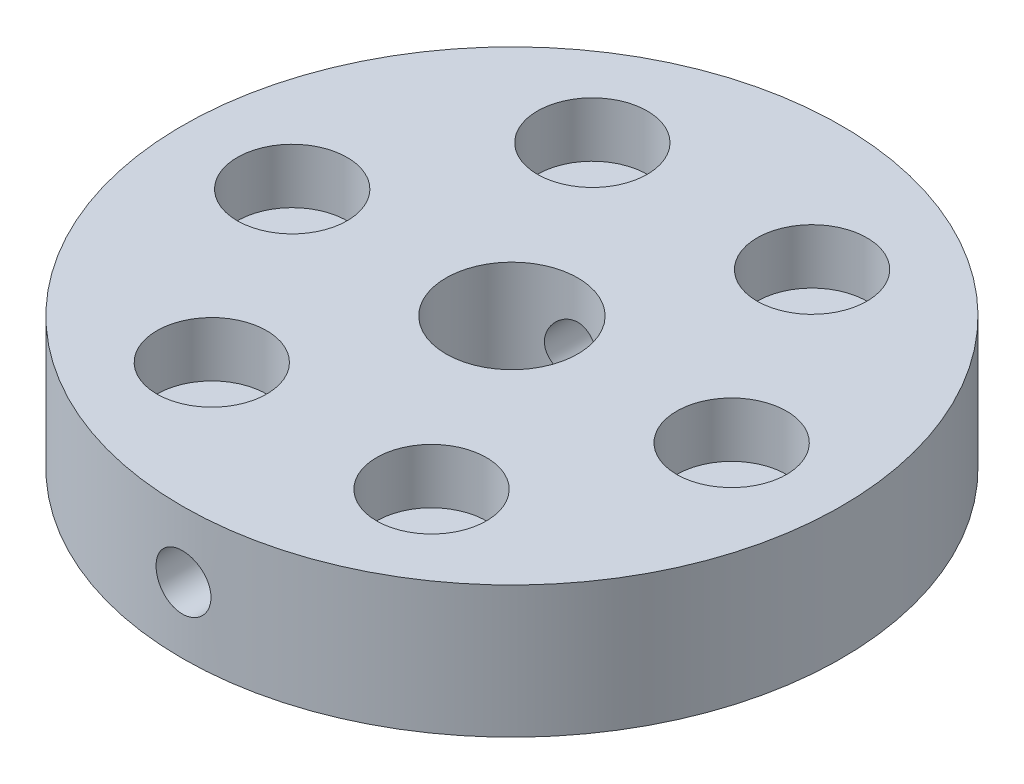
from build123d import *

# Parameters (mm, degrees)
SKETCH1_R               = 30
SKETCH1_R_2             = 2
SKETCH1_R_3             = 6
BOSS_EXTRUDE1_DEPTH     = 12
SKETCH2_R               = 2.5
CUT_EXTRUDE1_DEPTH      = 31
CUT_EXTRUDE1_DEPTH_BACK = 31
SKETCH3_R               = 5
CUT_EXTRUDE2_DEPTH      = 5


with BuildPart() as part:
    # Sketch1 → Boss-Extrude1 (new body)
    with BuildSketch(Plane(origin=(0, 0, 0), x_dir=(1, 0, 0), z_dir=(0, 1, 0))):
        Circle(SKETCH1_R)
        with Locations((20, 0)):
            Circle(SKETCH1_R_2, mode=Mode.SUBTRACT)
        with Locations((10, -17.320508076)):
            Circle(SKETCH1_R_2, mode=Mode.SUBTRACT)
        with Locations((-10, -17.320508076)):
            Circle(SKETCH1_R_2, mode=Mode.SUBTRACT)
        with Locations((-20, 0)):
            Circle(SKETCH1_R_2, mode=Mode.SUBTRACT)
        with Locations((-10, 17.320508076)):
            Circle(SKETCH1_R_2, mode=Mode.SUBTRACT)
        with Locations((10, 17.320508076)):
            Circle(SKETCH1_R_2, mode=Mode.SUBTRACT)
        Circle(SKETCH1_R_3, mode=Mode.SUBTRACT)
    extrude(amount=BOSS_EXTRUDE1_DEPTH)

    # Sketch2 → Cut-Extrude1 (cut, two sides)
    with BuildSketch(Plane.XY) as cut_extrude1_sk:
        with Locations((0, 6)):
            Circle(SKETCH2_R)
    extrude(amount=CUT_EXTRUDE1_DEPTH, mode=Mode.SUBTRACT)
    extrude(cut_extrude1_sk.sketch, amount=-CUT_EXTRUDE1_DEPTH_BACK, mode=Mode.SUBTRACT)

    # Sketch3 → Cut-Extrude2 (cut)
    with BuildSketch(Plane(origin=(0, 12, 0), x_dir=(1, 0, 0), z_dir=(0, 1, 0))):
        with Locations((-10, 17.320508076)):
            Circle(SKETCH3_R)
        with Locations((10, 17.320508076)):
            Circle(SKETCH3_R)
        with Locations((20, 0)):
            Circle(SKETCH3_R)
        with Locations((10, -17.320508076)):
            Circle(SKETCH3_R)
        with Locations((-10, -17.320508076)):
            Circle(SKETCH3_R)
        with Locations((-20, 0)):
            Circle(SKETCH3_R)
    extrude(amount=-CUT_EXTRUDE2_DEPTH, mode=Mode.SUBTRACT)


solid = part.part
